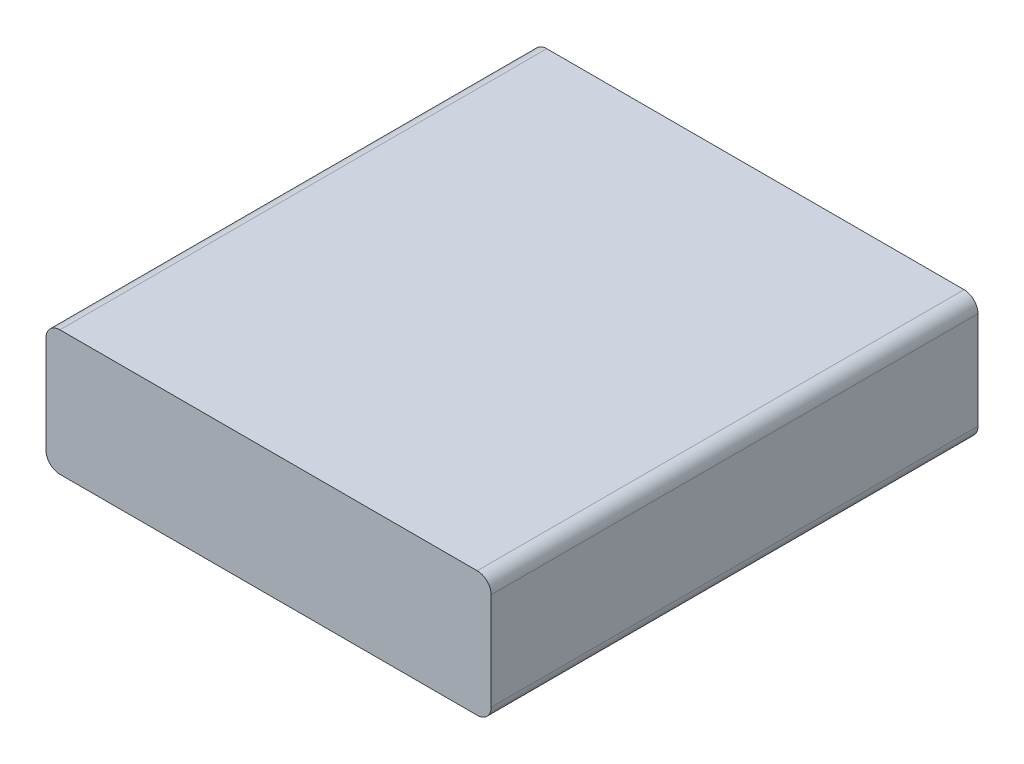
from build123d import *

# Parameters (mm, degrees)
SKETCH_1_W      = 64
SKETCH_1_H      = 18
EXTRUDE_1_DEPTH = 70
FILLET_1_R      = 2


with BuildPart() as part:
    # 草圖1 → 填料-伸長1 (new body)
    with BuildSketch(Plane.XY):
        with Locations((32, 9)):
            Rectangle(SKETCH_1_W, SKETCH_1_H)
    extrude(amount=EXTRUDE_1_DEPTH)

    # 圓角1
    fillet_1_edges = [part.edges().sort_by_distance(p)[0] for p in [
        (0, 18, 35),
        (64, 18, 35),
        (64, 0, 35),
        (0, 0, 35),
    ]]
    fillet(fillet_1_edges, radius=FILLET_1_R)


solid = part.part
